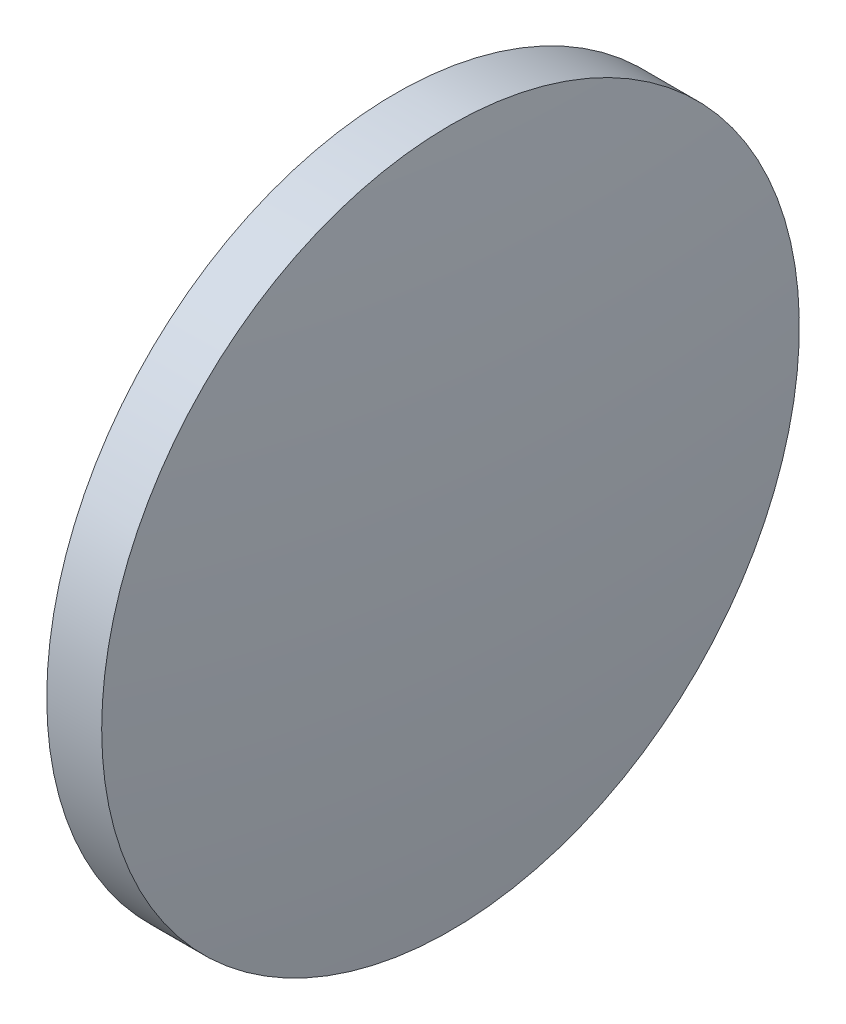
from build123d import *


with BuildPart() as part:
    # 草图1 → 旋转1 (revolve)
    with BuildSketch(Plane.XY):
        with BuildLine():
            Line((853.476577845, 273.088745717), (853.476577845, 285.788745717))
            Line((853.476577845, 285.788745717), (855.476577845, 285.788745717))
            ThreePointArc((855.476577845, 285.788745717), (856.001445134, 279.448384072), (856.176577845, 273.088745717))
            Line((856.176577845, 273.088745717), (853.476577845, 273.088745717))
        make_face()
    revolve(axis=Axis((847.738359809, 273.088745717, 0), (1, 0, 0)))


solid = part.part
